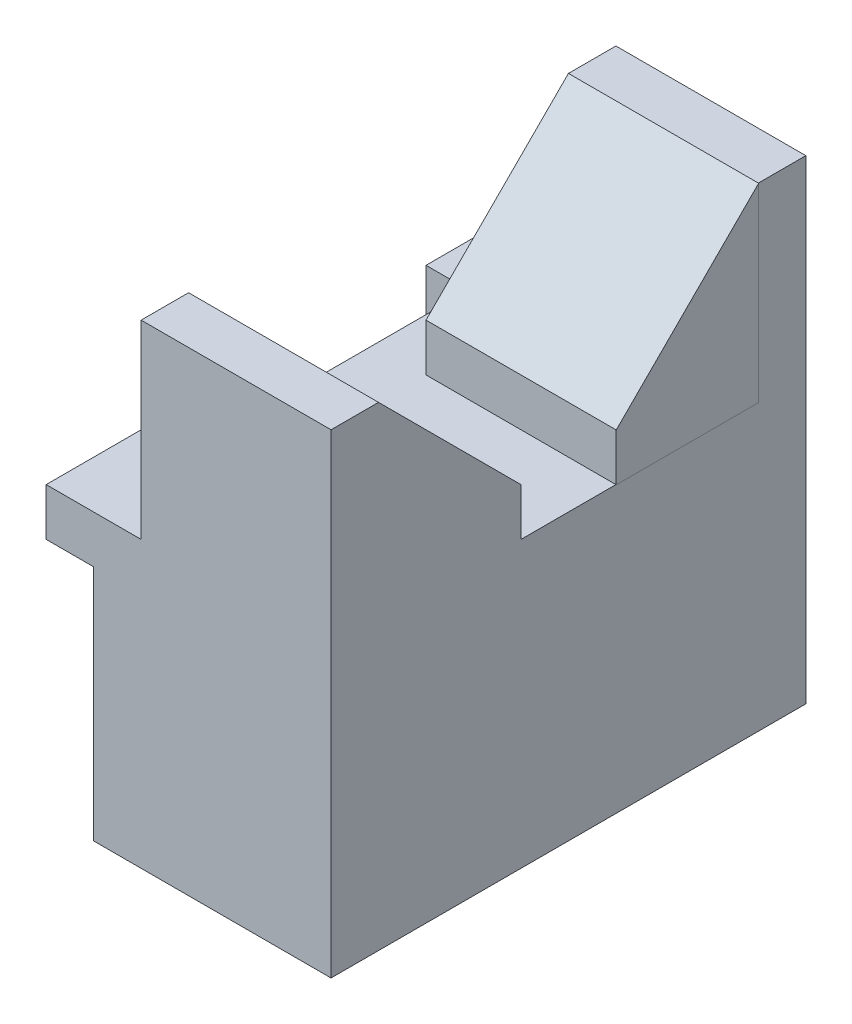
from build123d import *

# Parameters (mm, degrees)
SKETCH1_W            = 25
SKETCH1_H            = 50
BOSS_EXTRUDE1_DEPTH  = 25
SKETCH2_W            = 5
SKETCH2_H            = 10
BOSS_EXTRUDE2_DEPTH  = 5
SKETCH3_W            = 25
SKETCH3_H            = 50
BOSS_EXTRUDE3_DEPTH  = 5
SKETCH4_W            = 5
SKETCH4_H            = 10
BOSS_EXTRUDE5_DEPTH  = 5
SKETCH6_W            = 30.0479401
SKETCH6_H            = 5
BOSS_EXTRUDE6_DEPTH  = 0.5
SKETCH8_W            = 20
SKETCH8_H            = 5
BOSS_EXTRUDE7_DEPTH  = 20
SKETCH18_W           = 20
SKETCH18_H           = 15
BOSS_EXTRUDE9_DEPTH  = 20
CUT_EXTRUDE7_DEPTH   = 20
SKETCH15_W           = 20.034641196
SKETCH15_H           = 15
SKETCH15_W_2         = 20
SKETCH15_H_2         = 20
BOSS_EXTRUDE11_DEPTH = 20
CUT_EXTRUDE9_DEPTH   = 30


with BuildPart() as part:
    # Sketch1 → Boss-Extrude1 (new body)
    with BuildSketch(Plane(origin=(0, 0, 0), x_dir=(1, 0, 0), z_dir=(0, 1, 0))):
        with Locations((12.5, -25)):
            Rectangle(SKETCH1_W, SKETCH1_H)
    extrude(amount=BOSS_EXTRUDE1_DEPTH)



with BuildPart() as body_2:
    # Sketch2 → Boss-Extrude2 (new body)
    with BuildSketch(Plane(origin=(0, 25, 0), x_dir=(1, 0, 0), z_dir=(0, 1, 0))):
        with Locations((-2.5, -5)):
            Rectangle(SKETCH2_W, SKETCH2_H)
    extrude(amount=BOSS_EXTRUDE2_DEPTH)


with BuildPart() as part_1:
    add(part.part)

    add(body_2.part)  # Boss-Extrude3 merges body 2
    # Sketch3 → Boss-Extrude3 (add)
    with BuildSketch(Plane(origin=(0, 25, 0), x_dir=(1, 0, 0), z_dir=(0, 1, 0))):
        with Locations((12.5, -25)):
            Rectangle(SKETCH3_W, SKETCH3_H)
    extrude(amount=BOSS_EXTRUDE3_DEPTH)

    # Sketch4 → Boss-Extrude5 (add)
    with BuildSketch(Plane(origin=(0, 30, 0), x_dir=(1, 0, 0), z_dir=(0, 1, 0))):
        with Locations((-2.5, -45)):
            Rectangle(SKETCH4_W, SKETCH4_H)
    extrude(amount=-BOSS_EXTRUDE5_DEPTH)

    # Sketch6 → Boss-Extrude6 (add)
    with BuildSketch(Plane.ZY):
        with Locations((25.02397005, 27.5)):
            Rectangle(SKETCH6_W, SKETCH6_H)
    extrude(amount=BOSS_EXTRUDE6_DEPTH)

    # Sketch8 → Boss-Extrude7 (add)
    with BuildSketch(Plane(origin=(0, 30, 0), x_dir=(1, 0, 0), z_dir=(0, 1, 0))):
        with Locations((15, -2.5)):
            Rectangle(SKETCH8_W, SKETCH8_H)
    extrude(amount=BOSS_EXTRUDE7_DEPTH)

    # Sketch18 → Boss-Extrude9 (add)
    with BuildSketch(Plane(origin=(0, 30, 0), x_dir=(1, 0, 0), z_dir=(0, 1, 0))):
        with Locations((15, -42.5)):
            Rectangle(SKETCH18_W, SKETCH18_H)
    extrude(amount=BOSS_EXTRUDE9_DEPTH)

    # Sketch20 → Cut-Extrude7 (cut)
    with BuildSketch(Plane.ZY.offset(-5)):
        Polygon((45, 50), (35, 35), (35, 50), align=None)
    extrude(amount=-CUT_EXTRUDE7_DEPTH, mode=Mode.SUBTRACT)

    # Sketch15 → Boss-Extrude11 (add)
    with BuildSketch(Plane(origin=(0, 30, 0), x_dir=(1, 0, 0), z_dir=(0, 1, 0))):
        with Locations((15.017320598, -12.5)):
            Rectangle(SKETCH15_W, SKETCH15_H)
        with Locations((15, -40)):
            Rectangle(SKETCH15_W_2, SKETCH15_H_2)
    extrude(amount=BOSS_EXTRUDE11_DEPTH)

    # Sketch21 → Cut-Extrude9 (cut)
    with BuildSketch(Plane.ZY.offset(-5)):
        Polygon((5, 50), (20, 50), (20, 35), align=None)
        Polygon((45, 50), (30, 35), (30, 50), align=None)
    extrude(amount=-CUT_EXTRUDE9_DEPTH, mode=Mode.SUBTRACT)


solid = part_1.part
